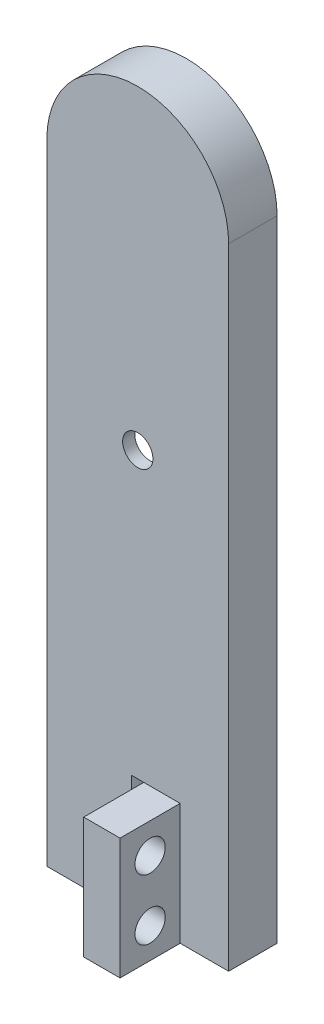
from build123d import *

# Parameters (mm, degrees)
EXTRUDE_1_DEPTH     = 4
CUT_EXTRUDE_1_DEPTH = 3
SKETCH_5_R          = 1.25
CUT_EXTRUDE_2_DEPTH = 12.4
SKETCH_6_W          = 1
SKETCH_6_H          = 10
CUT_EXTRUDE_3_DEPTH = 16.3
SKETCH_9_W          = 5
SKETCH_9_H          = 10
EXTRUDE_4_DEPTH     = 3
SKETCH_10_R         = 1.25
CUT_EXTRUDE_4_DEPTH = 5.1


with BuildPart() as part:
    # 草圖1 → 填料-伸長1 (new body)
    with BuildSketch(Plane.XY):
        with BuildLine():
            Line((7.5, 0), (7.5, 52))
            ThreePointArc((7.5, 52), (0, 59.5), (-7.5, 52))
            Line((-7.5, 52), (-7.5, 0))
            Line((-7.5, 0), (7.5, 0))
        make_face()
    extrude(amount=EXTRUDE_1_DEPTH)

    # 草圖3 → 除料-伸長1 (cut)
    with BuildSketch(Plane.XY):
        with BuildLine():
            ThreePointArc((-2.296635758, 50), (0, 52.296635758), (2.296635758, 50))
            Line((2.296635758, 50), (5, 33.5))
            Line((5, 33.5), (2.272331993, 16.632537074))
            ThreePointArc((2.272331993, 16.632537074), (-0.184323371, 14.705540024), (-2.301851795, 17))
            Line((-2.301851795, 17), (-5, 33.5))
            Line((-5, 33.5), (-2.296635758, 50))
        make_face()
    extrude(amount=CUT_EXTRUDE_1_DEPTH, mode=Mode.SUBTRACT)

    # 草圖5 → 除料-伸長2 (cut)
    with BuildSketch(Plane.XY):
        with Locations((0, 33.5)):
            Circle(SKETCH_5_R)
    extrude(amount=CUT_EXTRUDE_2_DEPTH, mode=Mode.SUBTRACT)

    # 草圖6 → 除料-伸長3 (cut)
    with BuildSketch(Plane.XY):
        with Locations((0, 5)):
            Rectangle(SKETCH_6_W, SKETCH_6_H)
    extrude(amount=CUT_EXTRUDE_3_DEPTH, mode=Mode.SUBTRACT)

    # 草圖9 → 填料-伸長4 (add)
    with BuildSketch(Plane(origin=(0.5, 0, 0), x_dir=(0, 0, -1), z_dir=(1, 0, 0))):
        with Locations((-6.46178466, 5)):
            Rectangle(SKETCH_9_W, SKETCH_9_H)
    extrude(amount=EXTRUDE_4_DEPTH)

    # 草圖10 → 除料-伸長4 (cut)
    with BuildSketch(Plane(origin=(0.5, 0, 0), x_dir=(0, 0, -1), z_dir=(1, 0, 0))):
        with Locations((-6.48089233, 7.5)):
            Circle(SKETCH_10_R)
        with Locations((-6.48089233, 2.5)):
            Circle(SKETCH_10_R)
    extrude(amount=CUT_EXTRUDE_4_DEPTH, mode=Mode.SUBTRACT)


solid = part.part
